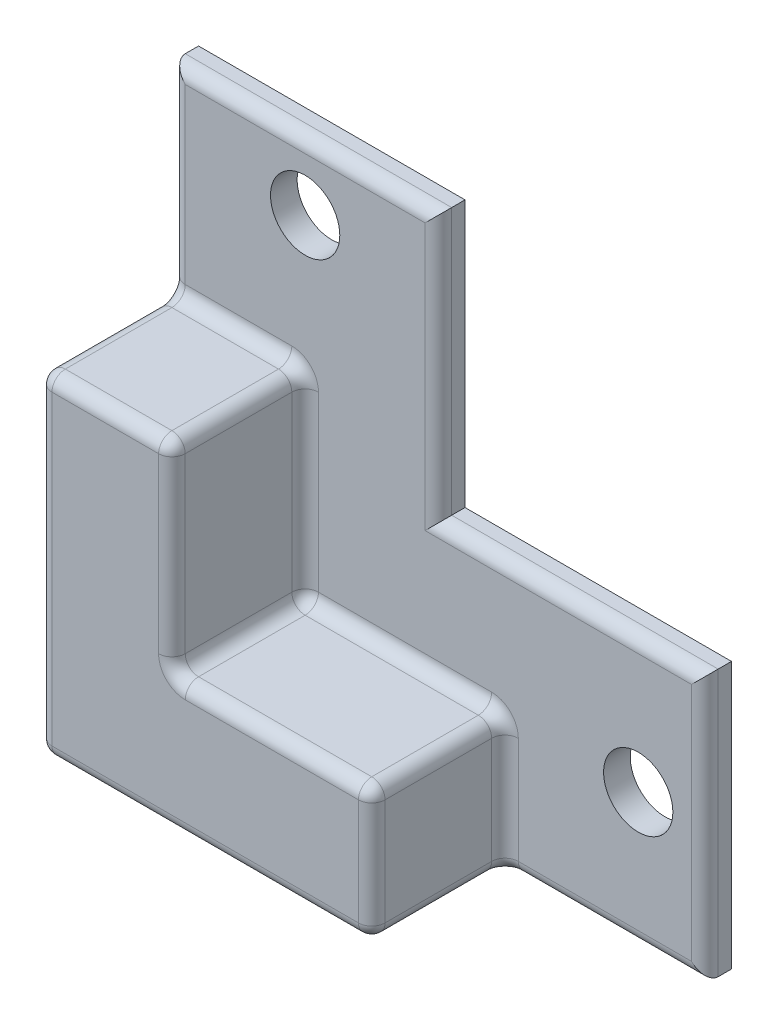
from build123d import *

# Parameters (mm, degrees)
SKETCH1_R           = 2.6
BOSS_EXTRUDE1_DEPTH = 2
BOSS_EXTRUDE2_DEPTH = 10
FILLET1_R           = 1


with BuildPart() as part:
    # Sketch1 → Boss-Extrude1 (new body)
    with BuildSketch(Plane.XY):
        Polygon((0, 20), (0, 0), (20, 0), (20, -20), (-20, -20), (-20, 20), align=None)
        with Locations((-10, 15)):
            Circle(SKETCH1_R, mode=Mode.SUBTRACT)
        with Locations((15, -10)):
            Circle(SKETCH1_R, mode=Mode.SUBTRACT)
    extrude(amount=BOSS_EXTRUDE1_DEPTH)

    # Sketch2 → Boss-Extrude2 (add)
    with BuildSketch(Plane.XY.offset(2)):
        Polygon((-10, 5), (-20, 5), (-20, -20), (5, -20), (5, -10), (-10, -10), align=None)
    extrude(amount=BOSS_EXTRUDE2_DEPTH)

    # Fillet1
    fillet1_edges = [part.edges().sort_by_distance(p)[0] for p in [
        (-20, -20, 6),
        (20, -10, 2),
        (10, 0, 2),
        (0, 10, 2),
        (-10, 20, 2),
        (12.5, -20, 2),
        (-10, -2.5, 2),
        (-10, -10, 7),
        (-15, 5, 2),
        (-10, 5, 7),
        (-20, 5, 7),
        (5, -15, 2),
        (5, -20, 7),
        (-2.5, -10, 2),
        (5, -10, 7),
        (-10, -2.5, 12),
        (-15, 5, 12),
        (-20, -7.5, 12),
        (-7.5, -20, 12),
        (5, -15, 12),
        (-2.5, -10, 12),
        (-20, 12.5, 2),
    ]]
    fillet(fillet1_edges, radius=FILLET1_R)


solid = part.part
